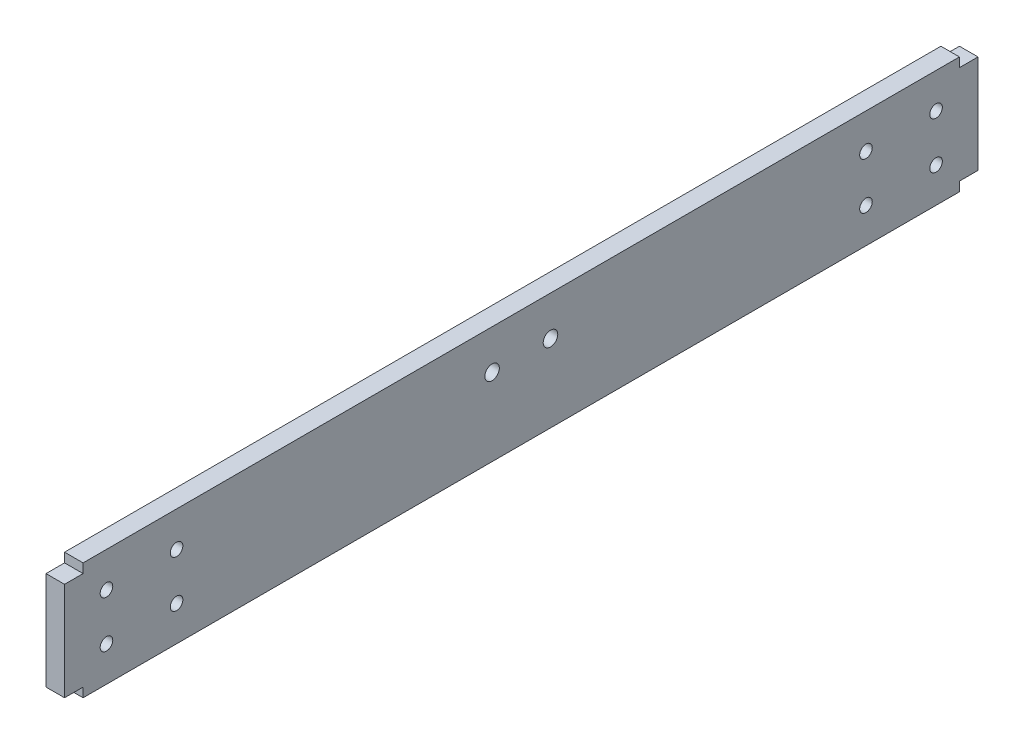
from build123d import *

# Parameters (mm, degrees)
SKETCH1_W              = 300
SKETCH1_H              = 40
BOSS_EXTRUDE1_DEPTH    = 6.35
SKETCH2_W              = 6.35
SKETCH2_H              = 33.65
BOSS_EXTRUDE2_DEPTH    = 6.35
F_10_CLEARANCE_HOLE1_D = 4.9784
F_8_CLEARANCE_HOLE1_D  = 4.3053


with BuildPart() as part:
    # Sketch1 → Boss-Extrude1 (new body)
    with BuildSketch(Plane(origin=(0, 0, 0), x_dir=(0, 0, -1), z_dir=(1, 0, 0))):
        Rectangle(SKETCH1_W, SKETCH1_H)
    extrude(amount=BOSS_EXTRUDE1_DEPTH)

    # Sketch2 → Boss-Extrude2 (add)
    with BuildSketch(Plane(origin=(6.35, 0, 0), x_dir=(0, 0, -1), z_dir=(1, 0, 0))):
        with Locations((-153.175, 0)):
            Rectangle(SKETCH2_W, SKETCH2_H)
        with Locations((153.175, 0)):
            Rectangle(SKETCH2_W, SKETCH2_H)
    extrude(amount=-BOSS_EXTRUDE2_DEPTH)

    # #10 Clearance Hole1 (through all)
    with Locations(Plane(origin=(6.35, 0, 0), x_dir=(0, 0, -1), z_dir=(1, 0, 0))):
        with Locations((-10, 6.5), (10, 6.5)):
            Hole(F_10_CLEARANCE_HOLE1_D / 2)

    # #8 Clearance Hole1 (through all)
    with Locations(Plane(origin=(6.35, 0, 0), x_dir=(0, 0, -1), z_dir=(1, 0, 0))):
        with Locations((-142, 8), (-118, 8), (-118, -8), (-142, -8), (118, 8), (142, 8), (142, -8), (118, -8)):
            Hole(F_8_CLEARANCE_HOLE1_D / 2)


solid = part.part
